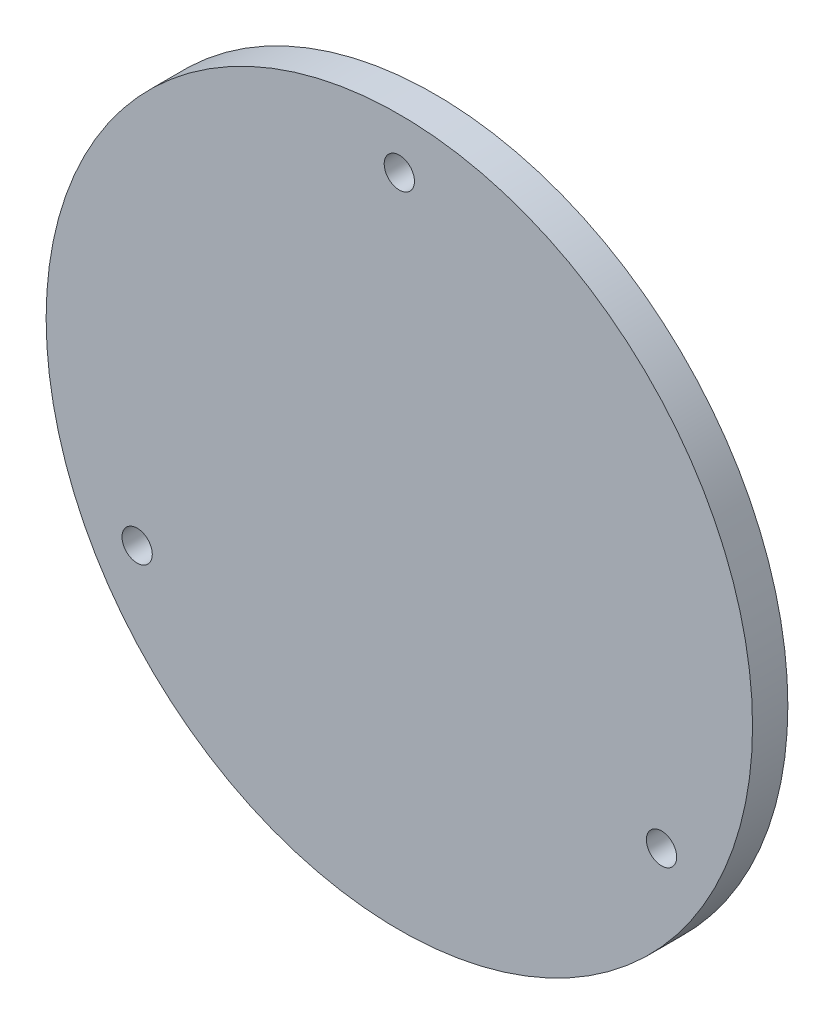
from build123d import *

# Parameters (mm, degrees)
SKETCH1_R           = 70
BOSS_EXTRUDE1_DEPTH = 7
SKETCH2_R           = 55
SKETCH2_R_2         = 50
BOSS_EXTRUDE2_DEPTH = 3
SKETCH3_R           = 3
CUT_EXTRUDE1_DEPTH  = 11


with BuildPart() as part:
    # Sketch1 → Boss-Extrude1 (new body)
    with BuildSketch(Plane.XY):
        Circle(SKETCH1_R)
    extrude(amount=BOSS_EXTRUDE1_DEPTH)

    # Sketch2 → Boss-Extrude2 (add)
    with BuildSketch(Plane(origin=(0, 0, 0), x_dir=(-1, 0, 0), z_dir=(0, 0, -1))):
        Circle(SKETCH2_R)
        Circle(SKETCH2_R_2, mode=Mode.SUBTRACT)
    extrude(amount=BOSS_EXTRUDE2_DEPTH)

    # Sketch3 → Cut-Extrude1 (cut, through all)
    with BuildSketch(Plane.XY.offset(7)):
        with Locations((0, 60)):
            Circle(SKETCH3_R)
        with Locations((51.961524227, -30)):
            Circle(SKETCH3_R)
        with Locations((-51.961524227, -30)):
            Circle(SKETCH3_R)
    extrude(amount=-CUT_EXTRUDE1_DEPTH, mode=Mode.SUBTRACT)


solid = part.part
